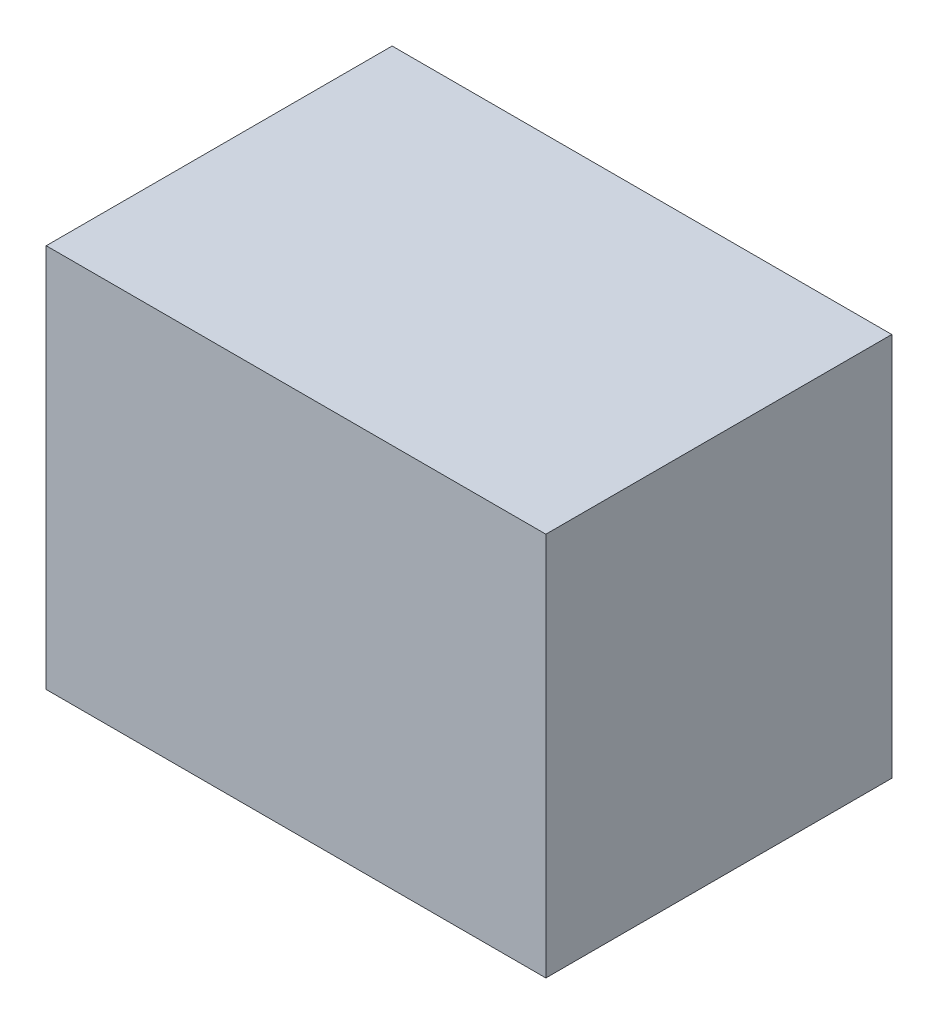
from build123d import *

# Parameters (mm, degrees)
SKETCH_1_W      = 130
SKETCH_1_H      = 90
EXTRUDE_1_DEPTH = 100


with BuildPart() as part:
    # 草图1 → 凸台-拉伸1 (new body)
    with BuildSketch(Plane(origin=(0, 0, 0), x_dir=(1, 0, 0), z_dir=(0, 1, 0))):
        Rectangle(SKETCH_1_W, SKETCH_1_H)
    extrude(amount=EXTRUDE_1_DEPTH)


solid = part.part
